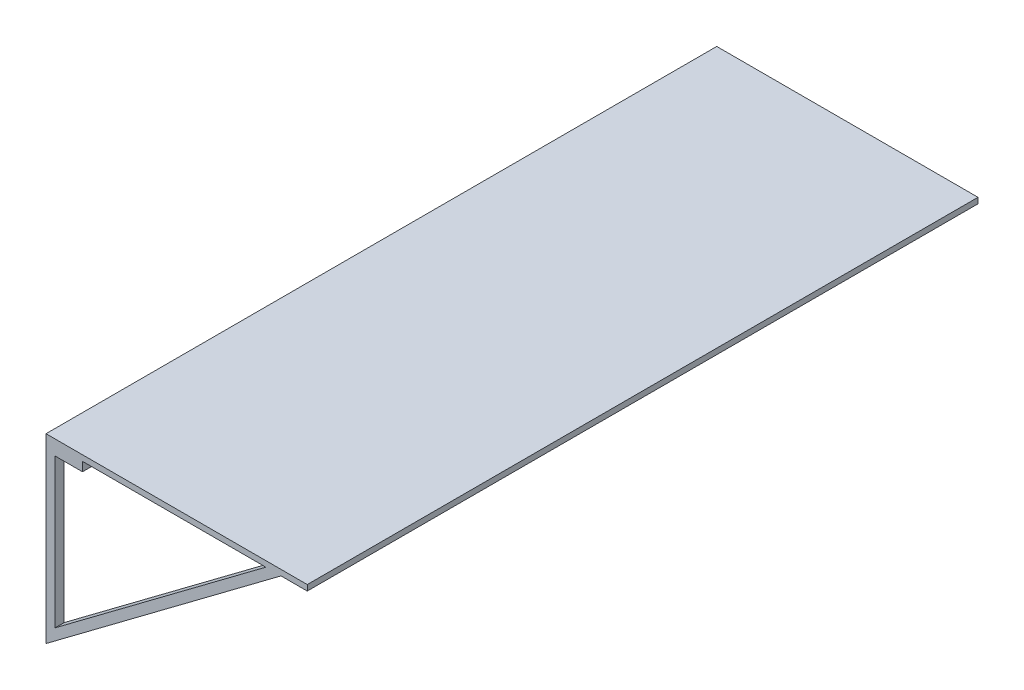
from build123d import *

# Parameters (mm, degrees)
BOSS_EXTRUDE1_DEPTH = 1874.774
SKETCH2_W           = 899.287
SKETCH2_H           = 492.125
CUT_EXTRUDE1_DEPTH  = 731.25


with BuildPart() as part:
    # Sketch1 → Boss-Extrude1 (new body)
    with BuildSketch(Plane.XY):
        Polygon((730.25, 492.125), (656.817236389, 492.125), (0, 0), (0, 508), (730.25, 508), align=None)
        Polygon((101.981819436, 492.125), (101.981819436, 466.725), (25.4, 466.725), (25.4, 50.769813509), (614.457036031, 492.125), align=None, mode=Mode.SUBTRACT)
    extrude(amount=BOSS_EXTRUDE1_DEPTH)

    # Sketch2 → Cut-Extrude1 (cut, through all)
    with BuildSketch(Plane(origin=(730.25, 0, 0), x_dir=(0, 0, -1), z_dir=(1, 0, 0))):
        with Locations((-1399.7305, 246.0625)):
            Rectangle(SKETCH2_W, SKETCH2_H)
        with Locations((-475.0435, 246.0625)):
            Rectangle(SKETCH2_W, SKETCH2_H)
    extrude(amount=-CUT_EXTRUDE1_DEPTH, mode=Mode.SUBTRACT)


solid = part.part
